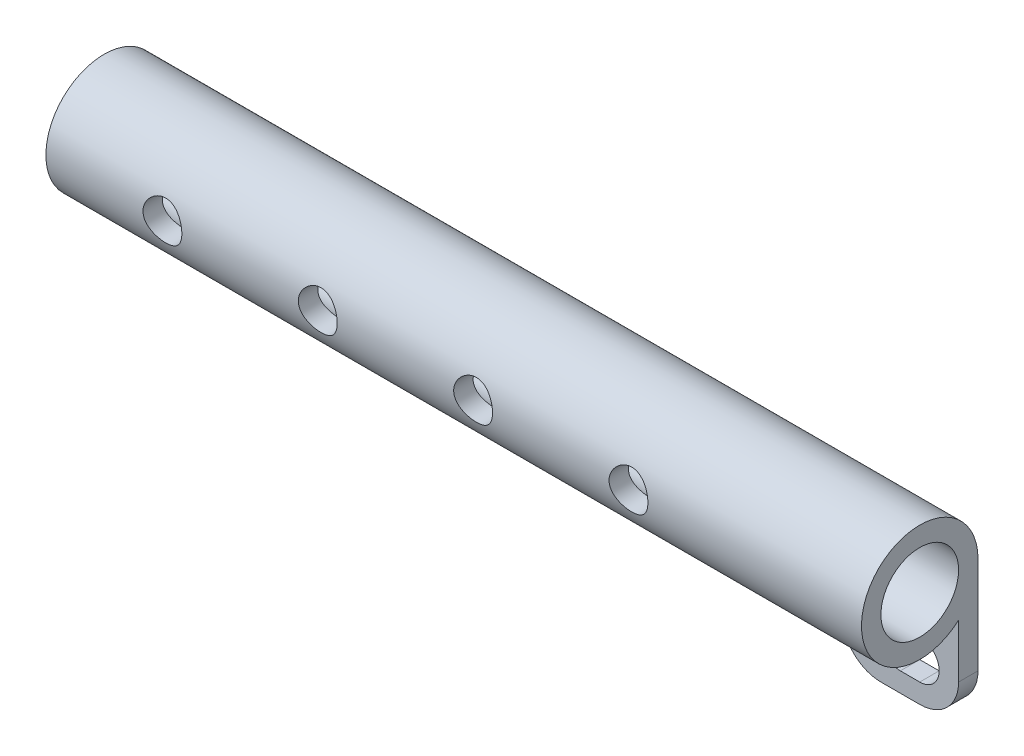
from build123d import *

# Parameters (mm, degrees)
SWEEP_THIN1_PROFILE_R   = 15
SWEEP_THIN1_PROFILE_R_2 = 10
SKETCH5_R               = 5
CUT_EXTRUDE1_DEPTH      = 288.452903629
CUT_EXTRUDE1_DEPTH_BACK = 288.452903629
BOSS_EXTRUDE2_DEPTH     = 5


with BuildPart() as part:
    # Sweep-Thin1: sweep along a path in Sketch2
    with BuildLine(Plane(origin=(0, 0, 0), x_dir=(1, 0, 0), z_dir=(0, 1, 0))) as sweep_thin1_path:
        Line((76.669098098, 180), (286.669098098, 180))
    # Sweep-Thin1 profile (on start of the path) → Sweep-Thin1 (sweep)
    with BuildSketch(Plane(origin=(76.669098098, 0, -180), x_dir=(0, 0, 1), z_dir=(1, 0, 0))):
        Circle(SWEEP_THIN1_PROFILE_R)
        Circle(SWEEP_THIN1_PROFILE_R_2, mode=Mode.SUBTRACT)
    sweep(path=sweep_thin1_path.line)

    # Sketch5 → Cut-Extrude1 (cut, two sides)
    with BuildSketch(Plane.XY.offset(-180)) as cut_extrude1_sk:
        with Locations((226.669098098, 0)):
            Circle(SKETCH5_R)
        with Locations((186.669098098, 0)):
            Circle(SKETCH5_R)
        with Locations((146.669098098, 0)):
            Circle(SKETCH5_R)
        with Locations((106.669098098, 0)):
            Circle(SKETCH5_R)
    extrude(amount=CUT_EXTRUDE1_DEPTH, mode=Mode.SUBTRACT)
    extrude(cut_extrude1_sk.sketch, amount=-CUT_EXTRUDE1_DEPTH_BACK, mode=Mode.SUBTRACT)

    # Sketch15 → Boss-Extrude2 (add)
    with BuildSketch(Plane(origin=(0, 0, -195), x_dir=(-1, 0, 0), z_dir=(0, 0, -1))):
        with BuildLine():
            Line((-286.669098098, 0), (-256.669098098, 0))
            Line((-256.669098098, 0), (-256.669098098, -25))
            ThreePointArc((-256.669098098, -25), (-259.598030287, -32.071067812), (-266.669098098, -35))
            Line((-266.669098098, -35), (-276.669098098, -35))
            ThreePointArc((-276.669098098, -35), (-283.74016591, -32.071067812), (-286.669098098, -25))
            Line((-286.669098098, -25), (-286.669098098, 0))
        make_face()
        with BuildLine():
            Line((-276.669098098, -20), (-271.669098098, -20))
            ThreePointArc((-271.669098098, -20), (-266.669098098, -25), (-271.669098098, -30))
            Line((-271.669098098, -30), (-276.669098098, -30))
            ThreePointArc((-276.669098098, -30), (-281.669098098, -25), (-276.669098098, -20))
        make_face(mode=Mode.SUBTRACT)
    extrude(amount=-BOSS_EXTRUDE2_DEPTH)


solid = part.part
